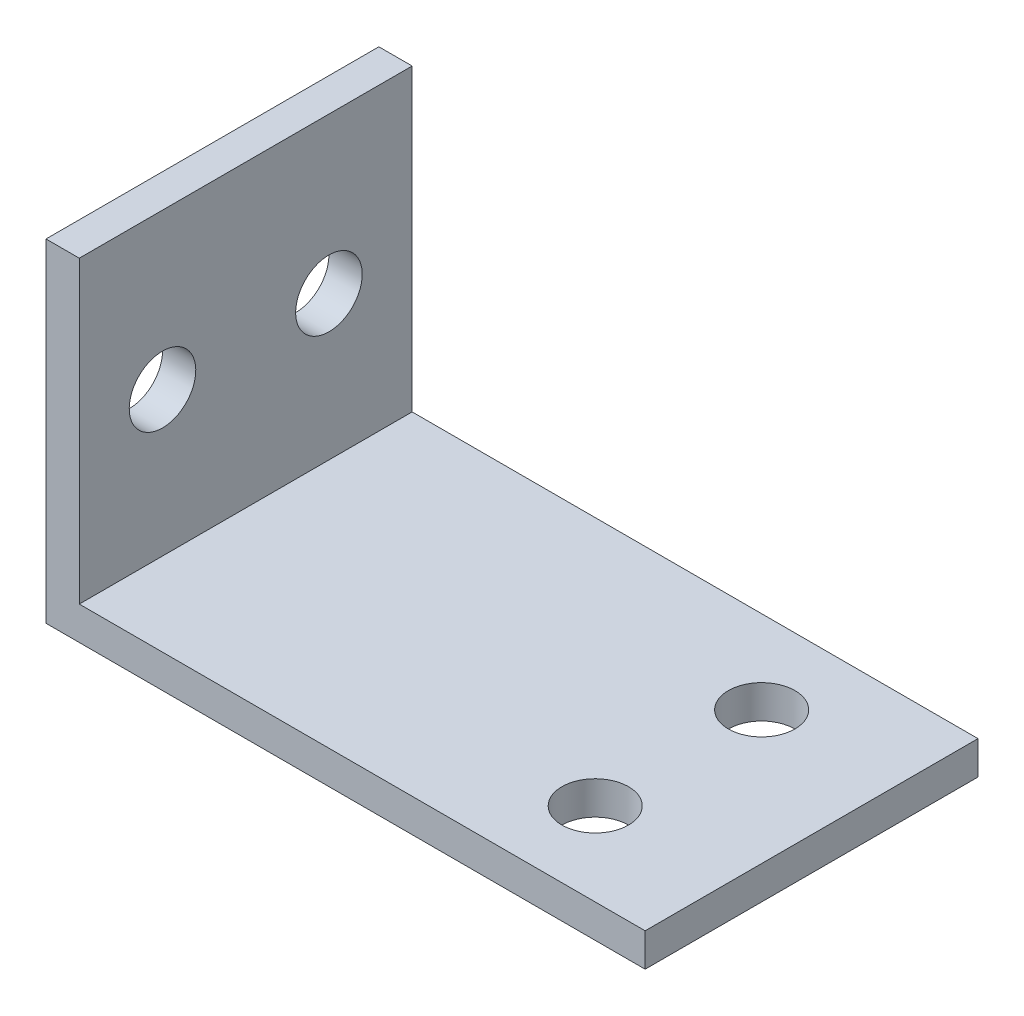
from build123d import *

# Parameters (mm, degrees)
AUFSATZ_LINEAR_AUSTRAGEN1_DEPTH      = 15
AUFSATZ_LINEAR_AUSTRAGEN1_DEPTH_BACK = 15
SKIZZE5_R                            = 3
SCHNITT_LINEAR_AUSTRAGEN1_DEPTH      = 24
SKIZZE7_R                            = 3
SCHNITT_LINEAR_AUSTRAGEN2_DEPTH      = 14


with BuildPart() as part:
    # Skizze2 → Aufsatz-Linear austragen1 (new body, two sides)
    with BuildSketch(Plane.XY) as aufsatz_linear_austragen1_sk:
        Polygon((14, 51), (11, 51), (11, 21), (65, 21), (65, 24), (14, 24), align=None)
    extrude(amount=AUFSATZ_LINEAR_AUSTRAGEN1_DEPTH)
    extrude(aufsatz_linear_austragen1_sk.sketch, amount=-AUFSATZ_LINEAR_AUSTRAGEN1_DEPTH_BACK)

    # Skizze5 → Schnitt-Linear austragen1 (cut)
    with BuildSketch(Plane(origin=(0, 0, 0), x_dir=(1, 0, 0), z_dir=(0, 1, 0))):
        with Locations((53, -7.5)):
            Circle(SKIZZE5_R)
        with Locations((53, 7.5)):
            Circle(SKIZZE5_R)
    extrude(amount=SCHNITT_LINEAR_AUSTRAGEN1_DEPTH, mode=Mode.SUBTRACT)

    # Skizze7 → Schnitt-Linear austragen2 (cut)
    with BuildSketch(Plane(origin=(0, 0, 0), x_dir=(0, 0, -1), z_dir=(1, 0, 0))):
        with Locations((7.5, 37)):
            Circle(SKIZZE7_R)
        with Locations((-7.5, 37)):
            Circle(SKIZZE7_R)
    extrude(amount=SCHNITT_LINEAR_AUSTRAGEN2_DEPTH, mode=Mode.SUBTRACT)


solid = part.part
